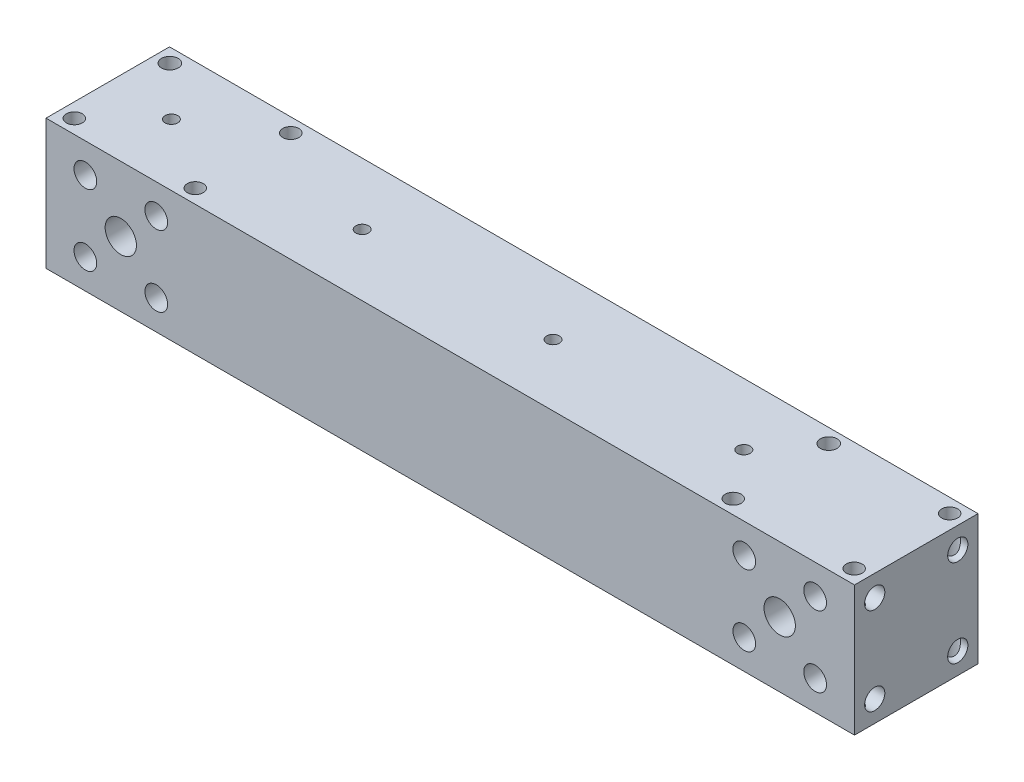
from build123d import *

# Parameters (mm, degrees)
SKETCH3_W           = 254
SKETCH3_H           = 38.8
BOSS_EXTRUDE1_DEPTH = 40.878125
SKETCH4_R           = 3.571875
SKETCH4_R_2         = 4.92125
CUT_EXTRUDE2_DEPTH  = 39.8
SKETCH3_3_R         = 2.5
SKETCH3_3_R_2       = 2.627
CUT_EXTRUDE3_DEPTH  = 41.878125
SKETCH5_R           = 2
CUT_EXTRUDE4_DEPTH  = 12.7
SKETCH6_R           = 3.175
CUT_EXTRUDE5_DEPTH  = 6.35
CUT_EXTRUDE6_START  = -254
SKETCH6_3_R         = 3.175
CUT_EXTRUDE6_DEPTH  = 6.35
SKETCH7_R           = 9.525
CUT_EXTRUDE7_DEPTH  = 21.0185


with BuildPart() as part:
    # Sketch3 → Boss-Extrude1 (new body)
    with BuildSketch(Plane(origin=(0, 0, 0), x_dir=(1, 0, 0), z_dir=(0, 1, 0))):
        with Locations((0, -19.4)):
            Rectangle(SKETCH3_W, SKETCH3_H)
    extrude(amount=BOSS_EXTRUDE1_DEPTH)

    # Sketch4 → Cut-Extrude2 (cut, through all)
    with BuildSketch(Plane.XY):
        with Locations((114.63551759, 31.57458009)):
            Circle(SKETCH4_R)
        with Locations((92.36448241, 31.57458009)):
            Circle(SKETCH4_R)
        with Locations((114.63551759, 9.30354491)):
            Circle(SKETCH4_R)
        with Locations((103.5, 20.4390625)):
            Circle(SKETCH4_R_2)
        with Locations((92.36448241, 9.30354491)):
            Circle(SKETCH4_R)
        with Locations((-92.36448241, 31.57458009)):
            Circle(SKETCH4_R)
        with Locations((-114.63551759, 31.57458009)):
            Circle(SKETCH4_R)
        with Locations((-103.5, 20.4390625)):
            Circle(SKETCH4_R_2)
        with Locations((-92.36448241, 9.30354491)):
            Circle(SKETCH4_R)
        with Locations((-114.63551759, 9.30354491)):
            Circle(SKETCH4_R)
    extrude(amount=CUT_EXTRUDE2_DEPTH, mode=Mode.SUBTRACT)

    # Sketch3_3 → Cut-Extrude3 (cut, through all)
    with BuildSketch(Plane(origin=(0, 0, 0), x_dir=(1, 0, 0), z_dir=(0, 1, 0))):
        with Locations((-122.5, -34.4)):
            Circle(SKETCH3_3_R)
        with Locations((-84.5, -34.4)):
            Circle(SKETCH3_3_R)
        with Locations((-122.5, -4.4)):
            Circle(SKETCH3_3_R_2)
        with Locations((-84.5, -4.4)):
            Circle(SKETCH3_3_R)
        with Locations((84.5, -34.4)):
            Circle(SKETCH3_3_R)
        with Locations((122.5, -34.4)):
            Circle(SKETCH3_3_R)
        with Locations((122.5, -4.4)):
            Circle(SKETCH3_3_R)
        with Locations((84.5, -4.4)):
            Circle(SKETCH3_3_R_2)
    extrude(amount=CUT_EXTRUDE3_DEPTH, mode=Mode.SUBTRACT)

    # Sketch5 → Cut-Extrude4 (cut)
    with BuildSketch(Plane(origin=(0, 40.878125, 0), x_dir=(1, 0, 0), z_dir=(0, 1, 0))):
        with Locations((-47.056, -19.4)):
            Circle(SKETCH5_R)
        with Locations((-107, -19.4)):
            Circle(SKETCH5_R)
        with Locations((12.888, -19.4)):
            Circle(SKETCH5_R)
        with Locations((72.832, -19.4)):
            Circle(SKETCH5_R)
    extrude(amount=-CUT_EXTRUDE4_DEPTH, mode=Mode.SUBTRACT)

    # Sketch6 → Cut-Extrude5 (cut)
    with BuildSketch(Plane.ZY.offset(127)):
        with Locations((6.35, 34.188019491)):
            Circle(SKETCH6_R)
        with Locations((32.45, 34.188019491)):
            Circle(SKETCH6_R)
        with Locations((32.45, 6.690105509)):
            Circle(SKETCH6_R)
        with Locations((6.35, 6.690105509)):
            Circle(SKETCH6_R)
    extrude(amount=-CUT_EXTRUDE5_DEPTH, mode=Mode.SUBTRACT)

    # Sketch6_3 → Cut-Extrude6 (cut)
    with BuildSketch(Plane.ZY.offset(127).offset(CUT_EXTRUDE6_START)):
        with Locations((6.35, 34.188019491)):
            Circle(SKETCH6_3_R)
        with Locations((32.45, 34.188019491)):
            Circle(SKETCH6_3_R)
        with Locations((32.45, 6.690105509)):
            Circle(SKETCH6_3_R)
        with Locations((6.35, 6.690105509)):
            Circle(SKETCH6_3_R)
    extrude(amount=CUT_EXTRUDE6_DEPTH, mode=Mode.SUBTRACT)

    # Sketch7 → Cut-Extrude7 (cut)
    with BuildSketch(Plane(origin=(0, 0, 0), x_dir=(-1, 0, 0), z_dir=(0, 0, -1))):
        with Locations((-103.5, 20.4390625)):
            Circle(SKETCH7_R)
        with Locations((103.5, 20.4390625)):
            Circle(SKETCH7_R)
    extrude(amount=-CUT_EXTRUDE7_DEPTH, mode=Mode.SUBTRACT)


solid = part.part
